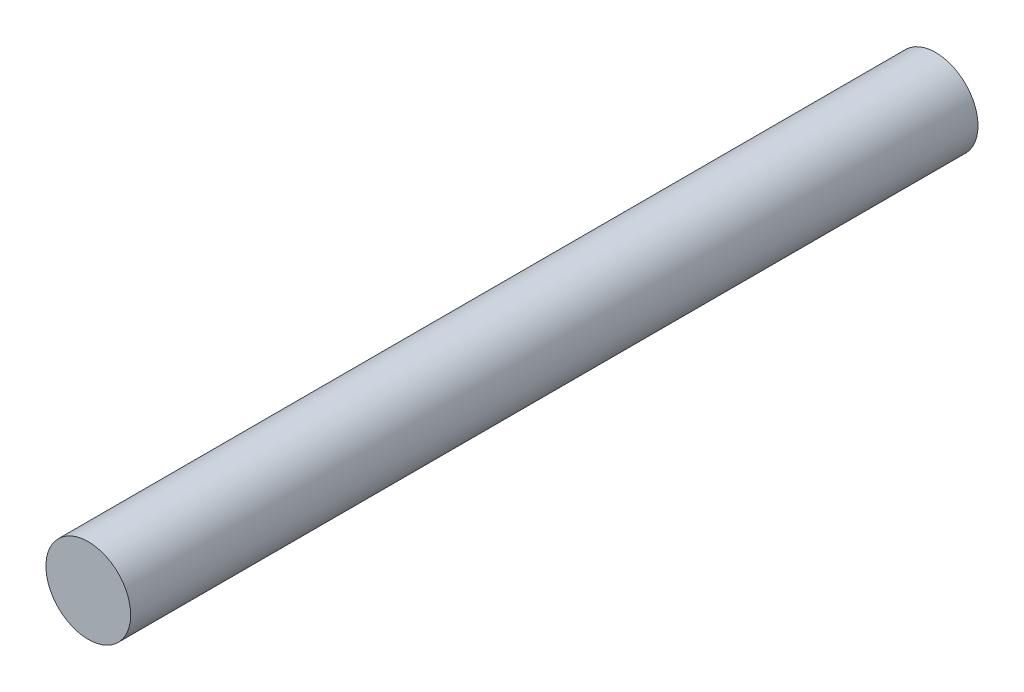
from build123d import *

# Parameters (mm, degrees)
SKETCH_1_R      = 4
EXTRUDE_1_DEPTH = 80


with BuildPart() as part:
    # 草图1 → 凸台-拉伸1 (new body)
    with BuildSketch(Plane.XY):
        with Locations((71.833058385, 2.819493448)):
            Circle(SKETCH_1_R)
    extrude(amount=EXTRUDE_1_DEPTH)


solid = part.part
